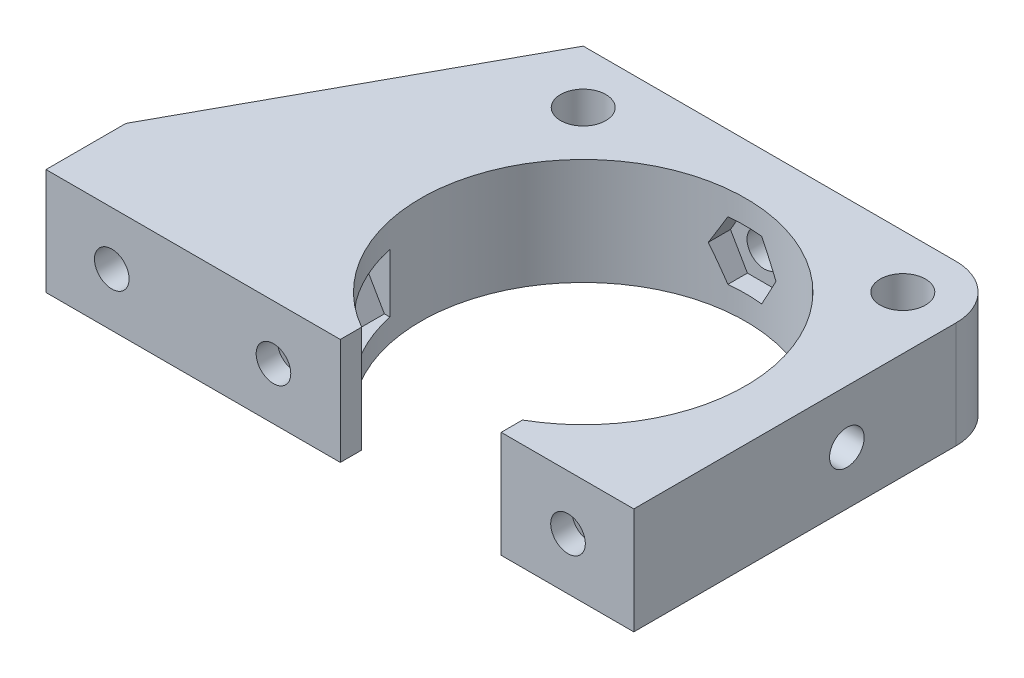
from build123d import *

# Parameters (mm, degrees)
CROQUIS1_R                              = 15.25
CROQUIS1_R_2                            = 2.125
SOPORTE_CAJA_REDUCTORA_DEPTH            = 20
CROQUIS3_R                              = 2.125
CORTAR_EXTRUIR1_DEPTH                   = 51.423828692
REDONDEO1_R                             = 5
BOSS_EXTRUDE1_DEPTH                     = 20
CUT_EXTRUDE1_REACH                      = 55.852
SKETCH2_R                               = 1.625
CUT_EXTRUDE2_DEPTH                      = 2
SKETCH4_R                               = 1.625
CUT_EXTRUDE3_DEPTH                      = 63.291652731
CUT_EXTRUDE4_START                      = -4.5
CUT_EXTRUDE4_DEPTH                      = 2
CROQUIS6_W                              = 4.75
CROQUIS6_H                              = 4.75
CORTAR_EXTRUIR17_DEPTH                  = 42.231056256
CROQUIS7_W                              = 60
CROQUIS7_H                              = 20
CORTAR_EXTRUIR18_DEPTH                  = 51.423828692
SALIENTE_EXTRUIR2_DEPTH                 = 49
SOPORTE_START                           = -15
SOPORTE_MOTOR_DEPTH                     = 15
CROQUIS12_R                             = 2.125
AGUJEROS_DE_SUJECION_A_BASE_DEPTH       = 84.087679592
TUERCA_START                            = -4
TUERCA_AGUJERO_DE_SUJECION_A_BASE_DEPTH = 10
SALIENTE_EXTRUIR4_DEPTH                 = 15
CORTAR_EXTRUIR19_DEPTH                  = 25
CROQUIS14_W                             = 50
CROQUIS14_H                             = 118
CORTAR_EXTRUIR22_DEPTH                  = 146.556045907
CROQUIS15_W                             = 10
CROQUIS15_H                             = 7
CORTAR_EXTRUIR23_DEPTH                  = 42.231056256
CORTAR_EXTRUIR24_DEPTH                  = 42.231056256
CROQUIS18_W                             = 40
CROQUIS18_H                             = 10
CORTAR_EXTRUIR25_DEPTH                  = 44.27311521
SALIENTE_EXTRUIR5_DEPTH                 = 10
CROQUIS20_R                             = 1
CORTAR_EXTRUIR26_DEPTH                  = 49.229270158
CORTAR_EXTRUIR27_REACH                  = 62.959
CORTAR_EXTRUIR27_END_RADIUS             = 15.25
CROQUIS21_R                             = 1.625
CROQUIS22_R                             = 2.125
CROQUIS22_R_2                           = 1
SALIENTE_EXTRUIR6_DEPTH                 = 10
CROQUIS23_R                             = 1.625
CORTAR_EXTRUIR28_DEPTH                  = 52.269508521
CORTAR_EXTRUIR29_START                  = -3
CORTAR_EXTRUIR29_DEPTH                  = 10
SALIENTE_EXTRUIR7_DEPTH                 = 10
CORTAR_EXTRUIR30_REACH                  = 72.235
CROQUIS27_R                             = 1.625
CORTAR_EXTRUIR31_REACH                  = 75.235
CORTAR_EXTRUIR31_START                  = -3
CORTAR_EXTRUIR32_REACH                  = 58.612
CROQUIS29_R                             = 1.625
CORTAR_EXTRUIR33_REACH                  = 61.112
CORTAR_EXTRUIR33_START                  = -2.5
CROQUIS35_W                             = 13.305418987
CROQUIS35_H                             = 6.826864192
CORTAR_EXTRUIR34_DEPTH                  = 63.931555098
CORTAR_EXTRUIR34_DEPTH_BACK             = 63.931555098
CORTAR_EXTRUIR35_START                  = -3
CORTAR_EXTRUIR35_DEPTH                  = 10
SALIENTE_EXTRUIR8_DEPTH                 = 10
SALIENTE_EXTRUIR9_DEPTH                 = 13
SALIENTE_EXTRUIR10_DEPTH                = 3
CROQUIS40_W                             = 106.583537839
CROQUIS40_H                             = 47.391515964
CORTAR_EXTRUIR36_DEPTH                  = 80.887064817
CORTAR_EXTRUIR36_DEPTH_BACK             = 80.887064817
CORTAR_EXTRUIR37_DEPTH                  = 67.2524009
CORTAR_EXTRUIR37_DEPTH_BACK             = 67.2524009
CORTAR_EXTRUIR38_DEPTH                  = 79.704784639
CORTAR_EXTRUIR38_DEPTH_BACK             = 79.704784639
SALIENTE_EXTRUIR11_DEPTH                = 10
CORTAR_EXTRUIR39_DEPTH                  = 63.9908649
CROQUIS45_W                             = 31.470301378
CROQUIS45_H                             = 10
CROQUIS45_R                             = 1.625
SALIENTE_EXTRUIR12_DEPTH                = 2.5
SALIENTE_EXTRUIR13_DEPTH                = 10
CORTAR_EXTRUIR40_START                  = -2
CROQUIS47_R                             = 1.625
CORTAR_EXTRUIR40_DEPTH                  = 10
CORTAR_EXTRUIR41_START                  = -12
CROQUIS48_R                             = 1.625
CORTAR_EXTRUIR41_DEPTH                  = 12
CORTAR_EXTRUIR42_DEPTH                  = 3
CROQUIS50_W                             = 80.415439526
CROQUIS50_H                             = 16.145703155
CORTAR_EXTRUIR43_DEPTH                  = 66.767385996
CORTAR_EXTRUIR43_DEPTH_BACK             = 66.767385996
CROQUIS51_R                             = 2.125
CORTAR_EXTRUIR44_DEPTH                  = 52.795622989
CORTAR_EXTRUIR44_DEPTH_BACK             = 52.795622989
CORTAR_EXTRUIR45_DEPTH                  = 52.795622989
CORTAR_EXTRUIR45_DEPTH_BACK             = 52.795622989
SALIENTE_EXTRUIR14_DEPTH                = 10
CORTAR_EXTRUIR46_START                  = -5.5
CORTAR_EXTRUIR46_DEPTH                  = 49.164449388


with BuildPart() as part:
    # Croquis1 → Soporte caja reductora (new body)
    with BuildSketch(Plane(origin=(0, 0, 0), x_dir=(1, 0, 0), z_dir=(0, 1, 0))):
        Polygon((-30, -15.25), (-20, -15.25), (-20, -20), (20, -20), (20, -15.25), (30, -15.25), (30, -7.25), (20, -4.25), (20, 20), (-20, 20), (-20, -4.25), (-30, -7.25), align=None)
        with Locations(Location((0, 0, 0), (0, 0, 270))):
            Circle(CROQUIS1_R, mode=Mode.SUBTRACT)
        with Locations(Location((-15, 15, 0), (0, 0, 270))):
            Circle(CROQUIS1_R_2, mode=Mode.SUBTRACT)
        with Locations(Location((15, 15, 0), (0, 0, 270))):
            Circle(CROQUIS1_R_2, mode=Mode.SUBTRACT)
    extrude(amount=-SOPORTE_CAJA_REDUCTORA_DEPTH)

    # Croquis3 → Cortar-Extruir1 (cut, through all)
    with BuildSketch(Plane.XY.offset(15.25)):
        with Locations((-23.5, -10)):
            Circle(CROQUIS3_R)
        with Locations((23.5, -10)):
            Circle(CROQUIS3_R)
    extrude(amount=-CORTAR_EXTRUIR1_DEPTH, mode=Mode.SUBTRACT)

    # Redondeo1
    redondeo1_edges = [part.edges().sort_by_distance(p)[0] for p in [
        (-20, -10, -20),
        (20, -10, -20),
    ]]
    fillet(redondeo1_edges, radius=REDONDEO1_R)

    # Sketch1 → Boss-Extrude1 (add)
    with BuildSketch(Plane(origin=(0, 0, 0), x_dir=(1, 0, 0), z_dir=(0, 1, 0))):
        with BuildLine():
            Line((25.5, 15), (20, 15))
            ThreePointArc((20, 15), (18.535533906, 18.535533906), (15, 20))
            Line((15, 20), (30, 20))
            Line((30, 20), (30, 8))
            Line((30, 8), (25.5, 8))
            Line((25.5, 8), (25.5, 15))
        make_face()
    extrude(amount=-BOSS_EXTRUDE1_DEPTH)

    # Sketch2 → Cut-Extrude1 (cut, up to next)
    with BuildSketch(Plane(origin=(0, 0, -20), x_dir=(-1, 0, 0), z_dir=(0, 0, -1)), mode=Mode.PRIVATE) as cut_extrude1_sk1:
        with Locations((-22.75, -10)):
            Circle(SKETCH2_R)
    cut_extrude1_tool1 = extrude(cut_extrude1_sk1.sketch, amount=-CUT_EXTRUDE1_REACH, mode=Mode.PRIVATE) & part.part
    add(cut_extrude1_tool1.solids().sort_by_distance((22.75, -10, -20))[0], mode=Mode.SUBTRACT)

    # Sketch3 → Cut-Extrude2 (cut)
    with BuildSketch(Plane.XY.offset(-15)):
        Polygon((20, -11.58771324), (22.75, -13.175426481), (25.5, -11.58771324), (25.5, -8.41228676), (22.75, -6.824573519), (20, -8.41228676), align=None)
    extrude(amount=-CUT_EXTRUDE2_DEPTH, mode=Mode.SUBTRACT)

    # Sketch4 → Cut-Extrude3 (cut, through all)
    with BuildSketch(Plane.ZY.offset(-25.5)):
        with Locations((-12.25, -10)):
            Circle(SKETCH4_R)
    extrude(amount=-CUT_EXTRUDE3_DEPTH, mode=Mode.SUBTRACT)

    # Sketch5 → Cut-Extrude4 (cut)
    with BuildSketch(Plane(origin=(30, 0, 0), x_dir=(0, 0, -1), z_dir=(1, 0, 0)).offset(CUT_EXTRUDE4_START)):
        Polygon((15, -11.58771324), (15, -8.41228676), (12.25, -6.824573519), (9.5, -8.41228676), (9.5, -11.58771324), (12.25, -13.175426481), align=None)
    extrude(amount=CUT_EXTRUDE4_DEPTH, mode=Mode.SUBTRACT)

    # Croquis6 → Cortar-Extruir17 (cut, through all)
    with BuildSketch(Plane(origin=(0, 0, 0), x_dir=(1, 0, 0), z_dir=(0, 1, 0))):
        Polygon((0, -15.25), (-15.25, -15.25), (-15.25, -20), (15.25, -20), (15.25, -15.25), align=None)
        with Locations((-17.625, -17.625)):
            Rectangle(CROQUIS6_W, CROQUIS6_H)
        with BuildLine():
            ThreePointArc((0, -15.25), (-10.783378413, -10.783378413), (-15.25, 0))
            Line((-15.25, 0), (-15.25, -15.25))
            Line((-15.25, -15.25), (0, -15.25))
        make_face()
        with BuildLine():
            Line((15.25, -15.25), (15.25, 0))
            ThreePointArc((15.25, 0), (10.783378413, -10.783378413), (0, -15.25))
            Line((0, -15.25), (15.25, -15.25))
        make_face()
        with Locations((17.625, -17.625)):
            Rectangle(CROQUIS6_W, CROQUIS6_H)
    extrude(amount=-CORTAR_EXTRUIR17_DEPTH, mode=Mode.SUBTRACT)


with BuildPart() as body_2:
    # Simetría1: mirrored copy
    add(part.part.mirror(Plane.ZX))

    # Croquis8 → Saliente-Extruir2 (add)
    with BuildSketch(Plane(origin=(0, 20, 0), x_dir=(1, 0, 0), z_dir=(0, 1, 0))):
        with BuildLine():
            Line((-12.664515522, 20), (-11.040489496, 13.939052358))
            Line((-11.040489496, 13.939052358), (-10.315162126, 11.232093763))
            ThreePointArc((-10.315162126, 11.232093763), (0, 15.25), (10.315162126, 11.232093763))
            Line((10.315162126, 11.232093763), (10.817418481, 13.87928066))
            Line((10.817418481, 13.87928066), (11.978715476, 20))
            Line((11.978715476, 20), (-12.664515522, 20))
        make_face()
    extrude(amount=SALIENTE_EXTRUIR2_DEPTH)

    # Croquis9 → Soporte motor (add)
    with BuildSketch(Plane(origin=(0, 69, 0), x_dir=(1, 0, 0), z_dir=(0, 1, 0)).offset(SOPORTE_START)):
        with BuildLine():
            Line((-20, 15), (-20, -4.25))
            Line((-20, -4.25), (-30, -7.25))
            Line((-30, -7.25), (-30, -15.25))
            Line((-30, -15.25), (0, -15.25))
            Line((0, -15.25), (0, -14.75))
            ThreePointArc((0, -14.75), (-10.429825023, 10.429825023), (14.75, 0))
            Line((14.75, 0), (20, 0))
            Line((20, 0), (20, 13.936837101))
            Line((20, 13.936837101), (12.664515522, 20))
            Line((12.664515522, 20), (-15, 20))
            ThreePointArc((-15, 20), (-18.535533906, 18.535533906), (-20, 15))
        make_face()
    extrude(amount=-SOPORTE_MOTOR_DEPTH)

    # Croquis12 → Agujeros de sujecion a base (cut, through all)
    with BuildSketch(Plane.XY.offset(15.25)):
        with Locations((-23.5, 46.5)):
            Circle(CROQUIS12_R)
    extrude(amount=-AGUJEROS_DE_SUJECION_A_BASE_DEPTH, mode=Mode.SUBTRACT)

    # Croquis13 → Tuerca Agujero de sujecion a base (cut)
    with BuildSketch(Plane.XY.offset(15.25).offset(TUERCA_START)):
        Polygon((-20, 44.479274058), (-20, 48.520725942), (-23.5, 50.541451884), (-27, 48.520725942), (-27, 44.479274058), (-23.5, 42.458548116), align=None)
    extrude(amount=-TUERCA_AGUJERO_DE_SUJECION_A_BASE_DEPTH, mode=Mode.SUBTRACT)

    # Croquis10 → Saliente-Extruir4 (add)
    with BuildSketch(Plane(origin=(0, 69, 0), x_dir=(1, 0, 0), z_dir=(0, 1, 0))):
        with BuildLine():
            ThreePointArc((10.315162126, 11.232093763), (0, 15.25), (-10.315162126, 11.232093763))
            Line((-10.315162126, 11.232093763), (-10.16850369, 10.684757026))
            ThreePointArc((-10.16850369, 10.684757026), (0, 14.75), (10.16850369, 10.684757026))
            Line((10.16850369, 10.684757026), (10.315162126, 11.232093763))
        make_face()
    extrude(amount=-SALIENTE_EXTRUIR4_DEPTH)

    # Croquis11 → Cortar-Extruir19 (cut)
    with BuildSketch(Plane.XZ):
        with BuildLine():
            Line((15.25, 4.25), (20, 4.25))
            Line((20, 4.25), (21.972856468, 4.84185694))
            ThreePointArc((21.972856468, 4.84185694), (19.948931102, 10.40625523), (16.543503257, 15.25))
            Line((16.543503257, 15.25), (15.25, 15.25))
            Line((15.25, 15.25), (15.25, 4.25))
        make_face()
        with BuildLine():
            Line((21.972856468, 4.84185694), (30, 7.25))
            Line((30, 7.25), (30, 15.25))
            Line((30, 15.25), (16.543503257, 15.25))
            ThreePointArc((16.543503257, 15.25), (19.948931102, 10.40625523), (21.972856468, 4.84185694))
        make_face()
        with BuildLine():
            ThreePointArc((20, -15), (18.535533906, -18.535533906), (15, -20))
            Line((15, -20), (30, -20))
            Line((30, -20), (30, -8))
            Line((30, -8), (25.5, -8))
            Line((25.5, -8), (25.5, -15))
            Line((25.5, -15), (20, -15))
        make_face()
    extrude(amount=-CORTAR_EXTRUIR19_DEPTH, mode=Mode.SUBTRACT)

    # Simetría2: body 2 across face


with BuildPart() as part_1:
    add(part.part)

    # Croquis7 → Cortar-Extruir18 (cut, through all)
    with BuildSketch(Plane(origin=(0, 0, -20), x_dir=(-1, 0, 0), z_dir=(0, 0, -1))):
        with Locations((0, -10)):
            Rectangle(CROQUIS7_W, CROQUIS7_H)
    extrude(amount=-CORTAR_EXTRUIR18_DEPTH, mode=Mode.SUBTRACT)


with BuildPart() as body_2_1:
    add(body_2.part)
    add(body_2.part.mirror(Plane(origin=(-0.229209569, 69, -16.663998028), x_dir=(0, 0, 1), z_dir=(0, 1, 0))))

    # Croquis14 → Cortar-Extruir22 (cut, through all)
    with BuildSketch(Plane.XY.offset(15.25)):
        with Locations((-5, 79)):
            Rectangle(CROQUIS14_W, CROQUIS14_H)
    extrude(amount=-CORTAR_EXTRUIR22_DEPTH, mode=Mode.SUBTRACT)

    # Croquis15 → Cortar-Extruir23 (cut, through all)
    with BuildSketch(Plane.XZ):
        with Locations((-25, 7.75)):
            Rectangle(CROQUIS15_W, CROQUIS15_H)
    extrude(amount=-CORTAR_EXTRUIR23_DEPTH, mode=Mode.SUBTRACT)

    # Croquis16 → Cortar-Extruir24 (cut, through all)
    with BuildSketch(Plane.XZ):
        Polygon((-30, 15.25), (-15.25, 15.25), (-15.25, 12.75), (-20, 12.75), (-20, 11.25), (-30, 11.25), (-30, 12.75), align=None)
    extrude(amount=-CORTAR_EXTRUIR24_DEPTH, mode=Mode.SUBTRACT)

    # Croquis18 → Cortar-Extruir25 (cut, through all)
    with BuildSketch(Plane(origin=(0, 0, -20), x_dir=(-1, 0, 0), z_dir=(0, 0, -1))):
        with Locations((0, 5)):
            Rectangle(CROQUIS18_W, CROQUIS18_H)
    extrude(amount=-CORTAR_EXTRUIR25_DEPTH, mode=Mode.SUBTRACT)

    # Croquis19 → Saliente-Extruir5 (add)
    with BuildSketch(Plane(origin=(0, 20, 0), x_dir=(1, 0, 0), z_dir=(0, 1, 0))):
        Polygon((-20, -12.75), (-34, -12.75), (-34, -7.75), (-24, -7.75), (-20, -3.75), align=None)
    extrude(amount=-SALIENTE_EXTRUIR5_DEPTH)

    # Croquis20 → Cortar-Extruir26 (cut, through all)
    with BuildSketch(Plane(origin=(0, 0, 7.75), x_dir=(-1, 0, 0), z_dir=(0, 0, -1))):
        with Locations((29, 15)):
            Circle(CROQUIS20_R)
    extrude(amount=-CORTAR_EXTRUIR26_DEPTH, mode=Mode.SUBTRACT)

    # Cortar-Extruir27: up to this cylinder (the profile starts outside it)
    cortar_extruir27_end = Plane(origin=(0, 15, 0), z_dir=(0, -1, 0)) * Cylinder(CORTAR_EXTRUIR27_END_RADIUS, 157.418, mode=Mode.PRIVATE)
    # Croquis21 → Cortar-Extruir27 (cut, up to the surface)
    with BuildSketch(Plane(origin=(20, 0, 0), x_dir=(0, 0, -1), z_dir=(1, 0, 0)), mode=Mode.PRIVATE) as cortar_extruir27_sk1:
        with Locations((4.75, 15)):
            Circle(CROQUIS21_R)
    cortar_extruir27_tool1 = extrude(cortar_extruir27_sk1.sketch, amount=-CORTAR_EXTRUIR27_REACH, mode=Mode.PRIVATE) - cortar_extruir27_end
    add(cortar_extruir27_tool1.solids().sort_by_distance((20, 15, -4.75))[0], mode=Mode.SUBTRACT)

    # Croquis22 → Saliente-Extruir6 (add)
    with BuildSketch(Plane.XZ.offset(-10)):
        with Locations((-15, -15)):
            Circle(CROQUIS22_R)
        with Locations(Location((-15, -15, 0), (0, 0, 270))):
            Circle(CROQUIS22_R_2, mode=Mode.SUBTRACT)
        with Locations((15, -15)):
            Circle(CROQUIS22_R)
        with Locations(Location((15, -15, 0), (0, 0, 270))):
            Circle(CROQUIS22_R_2, mode=Mode.SUBTRACT)
    extrude(amount=-SALIENTE_EXTRUIR6_DEPTH)

    # Croquis23 → Cortar-Extruir28 (cut, through all)
    with BuildSketch(Plane(origin=(0, 0, -20), x_dir=(-1, 0, 0), z_dir=(0, 0, -1))):
        with Locations((0, 15)):
            Circle(CROQUIS23_R)
    extrude(amount=-CORTAR_EXTRUIR28_DEPTH, mode=Mode.SUBTRACT)

    # Croquis24 → Cortar-Extruir29 (cut)
    with BuildSketch(Plane(origin=(0, 0, -20), x_dir=(-1, 0, 0), z_dir=(0, 0, -1)).offset(CORTAR_EXTRUIR29_START)):
        Polygon((1.58771324, 12.25), (3.175426481, 15), (1.58771324, 17.75), (-1.58771324, 17.75), (-3.175426481, 15), (-1.58771324, 12.25), align=None)
    extrude(amount=-CORTAR_EXTRUIR29_DEPTH, mode=Mode.SUBTRACT)

    # Croquis26 → Saliente-Extruir7 (add)
    with BuildSketch(Plane.XZ.offset(-10)):
        Polygon((-34, 7.75), (-34, 12.75), (-58.825, 12.75), (-39.160527763, -4.104491148), (-20, -4.104491148), (-20, -0.104491148), (-35.732113118, -0.104491148), (-29, 7.75), align=None)
        Polygon((-34.268209086, 7.75), (-39.594516123, 1.535690951), (-46.844874897, 7.75), align=None, mode=Mode.SUBTRACT)
    extrude(amount=-SALIENTE_EXTRUIR7_DEPTH)

    # Croquis27 → Cortar-Extruir30 (cut, up to next)
    with BuildSketch(Plane.XY.offset(12.75), mode=Mode.PRIVATE) as cortar_extruir30_sk1:
        with Locations((-40.544874897, 15)):
            Circle(CROQUIS27_R)
    cortar_extruir30_tool1 = extrude(cortar_extruir30_sk1.sketch, amount=-CORTAR_EXTRUIR30_REACH, mode=Mode.PRIVATE) & body_2_1.part
    # Croquis27 → Cortar-Extruir30 (cut, up to next)
    with BuildSketch(Plane.XY.offset(12.75), mode=Mode.PRIVATE) as cortar_extruir30_sk2:
        with Locations((-29, 15)):
            Circle(CROQUIS27_R)
    cortar_extruir30_tool2 = extrude(cortar_extruir30_sk2.sketch, amount=-CORTAR_EXTRUIR30_REACH, mode=Mode.PRIVATE) & body_2_1.part
    add(cortar_extruir30_tool1.solids().sort_by_distance((-40.544875, 15, 12.75))[0], mode=Mode.SUBTRACT)
    add(cortar_extruir30_tool2.solids().sort_by_distance((-29, 15, 12.75))[0], mode=Mode.SUBTRACT)

    # Croquis28 → Cortar-Extruir31 (cut, up to next)
    with BuildSketch(Plane.XY.offset(12.75).offset(CORTAR_EXTRUIR31_START), mode=Mode.PRIVATE) as cortar_extruir31_sk1:
        Polygon((-38.957161657, 12.25), (-37.369448416, 15), (-38.957161657, 17.75), (-42.132588137, 17.75), (-43.720301378, 15), (-42.132588137, 12.25), align=None)
    cortar_extruir31_tool1 = extrude(cortar_extruir31_sk1.sketch, amount=-CORTAR_EXTRUIR31_REACH, mode=Mode.PRIVATE) & body_2_1.part
    # Croquis28 → Cortar-Extruir31 (cut, up to next)
    with BuildSketch(Plane.XY.offset(12.75).offset(CORTAR_EXTRUIR31_START), mode=Mode.PRIVATE) as cortar_extruir31_sk2:
        Polygon((-27.41228676, 12.25), (-25.824573519, 15), (-27.41228676, 17.75), (-30.58771324, 17.75), (-32.175426481, 15), (-30.58771324, 12.25), align=None)
    cortar_extruir31_tool2 = extrude(cortar_extruir31_sk2.sketch, amount=-CORTAR_EXTRUIR31_REACH, mode=Mode.PRIVATE) & body_2_1.part
    add(cortar_extruir31_tool1.solids().sort_by_distance((-40.544875, 15, 9.75))[0], mode=Mode.SUBTRACT)
    add(cortar_extruir31_tool2.solids().sort_by_distance((-29, 15, 9.75))[0], mode=Mode.SUBTRACT)

    # Croquis29 → Cortar-Extruir32 (cut, up to next)
    with BuildSketch(Plane(origin=(-18.612848159, 0, -21.715982563), x_dir=(-0.7592713073348843, 0, 0.6507742172658468), z_dir=(-0.6507742172658468, 0, -0.7592713073348843)), mode=Mode.PRIVATE) as cortar_extruir32_sk1:
        with Locations((33.812368097, 15)):
            Circle(CROQUIS29_R)
    cortar_extruir32_tool1 = extrude(cortar_extruir32_sk1.sketch, amount=-CORTAR_EXTRUIR32_REACH, mode=Mode.PRIVATE) & body_2_1.part
    add(cortar_extruir32_tool1.solids().sort_by_distance((-44.285609, 15, 0.288235))[0], mode=Mode.SUBTRACT)

    # Croquis31 → Cortar-Extruir33 (cut, up to next)
    with BuildSketch(Plane(origin=(-18.612848159, 0, -21.715982563), x_dir=(-0.7592713073348843, 0, 0.6507742172658468), z_dir=(-0.6507742172658468, 0, -0.7592713073348843)).offset(CORTAR_EXTRUIR33_START), mode=Mode.PRIVATE) as cortar_extruir33_sk1:
        Polygon((36.562368097, 16.58771324), (33.812368097, 18.175426481), (31.062368097, 16.58771324), (31.062368097, 13.41228676), (33.812368097, 11.824573519), (36.562368097, 13.41228676), align=None)
    cortar_extruir33_tool1 = extrude(cortar_extruir33_sk1.sketch, amount=-CORTAR_EXTRUIR33_REACH, mode=Mode.PRIVATE) & body_2_1.part
    add(cortar_extruir33_tool1.solids().sort_by_distance((-42.658674, 15, 2.186413))[0], mode=Mode.SUBTRACT)

    # Croquis35 → Cortar-Extruir34 (cut, two sides)
    with BuildSketch(Plane(origin=(0, 20, 0), x_dir=(1, 0, 0), z_dir=(0, 1, 0))) as cortar_extruir34_sk:
        with Locations((17.04227466, -3.413432096)):
            Rectangle(CROQUIS35_W, CROQUIS35_H)
    extrude(amount=CORTAR_EXTRUIR34_DEPTH, mode=Mode.SUBTRACT)
    extrude(cortar_extruir34_sk.sketch, amount=-CORTAR_EXTRUIR34_DEPTH_BACK, mode=Mode.SUBTRACT)

    # Croquis36 → Cortar-Extruir35 (cut)
    with BuildSketch(Plane(origin=(20, 0, 0), x_dir=(0, 0, -1), z_dir=(1, 0, 0)).offset(CORTAR_EXTRUIR35_START)):
        Polygon((7.5, 16.58771324), (4.75, 18.175426481), (2, 16.58771324), (2, 13.41228676), (4.75, 11.824573519), (7.5, 13.41228676), align=None)
    extrude(amount=-CORTAR_EXTRUIR35_DEPTH, mode=Mode.SUBTRACT)

    # Croquis37 → Saliente-Extruir8 (add)
    with BuildSketch(Plane.XZ.offset(-10)):
        Polygon((-39.160527763, -4.104491148), (-20.614919368, -20), (-15, -20), (-19.558128305, -15.637570403), (-33.014002756, -4.104491148), align=None)
    extrude(amount=-SALIENTE_EXTRUIR8_DEPTH)

    # Croquis38 → Saliente-Extruir9 (add)
    with BuildSketch(Plane.XZ.offset(-10)):
        Polygon((-58.825, 12.75), (-38.825, 12.75), (-38.825, 9.75), (-55.324839942, 9.75), align=None)
    extrude(amount=SALIENTE_EXTRUIR9_DEPTH)

    # Croquis39 → Saliente-Extruir10 (add)
    with BuildSketch(Plane.XZ.offset(-10)):
        Polygon((-38.825, 9.75), (-38.825, 7.75), (-38.825, 5.75), (-50.657959865, 5.75), (-52.991399903, 7.75), (-55.324839942, 9.75), align=None)
    extrude(amount=SALIENTE_EXTRUIR10_DEPTH)

    # Simetría3: body 2 across face


with BuildPart() as body_2_2:
    add(body_2_1.part)
    add(body_2_1.part.mirror(Plane(origin=(-18.003999227, 20, -4.220503046), x_dir=(0, 0, 1), z_dir=(0, 1, 0))))

    # Croquis40 → Cortar-Extruir36 (cut, two sides)
    with BuildSketch(Plane(origin=(0, 0, -20), x_dir=(-1, 0, 0), z_dir=(0, 0, -1))) as cortar_extruir36_sk:
        with Locations((22.395502026, -3.695757982)):
            Rectangle(CROQUIS40_W, CROQUIS40_H)
    extrude(amount=CORTAR_EXTRUIR36_DEPTH, mode=Mode.SUBTRACT)
    extrude(cortar_extruir36_sk.sketch, amount=-CORTAR_EXTRUIR36_DEPTH_BACK, mode=Mode.SUBTRACT)

    # Croquis41 → Cortar-Extruir37 (cut, two sides)
    with BuildSketch(Plane.XZ.offset(-20)) as cortar_extruir37_sk:
        Polygon((-19.992980133, -22.302484261), (-20, 3.75), (-24, 7.75), (-56.035110209, 7.75), align=None)
    extrude(amount=CORTAR_EXTRUIR37_DEPTH, mode=Mode.SUBTRACT)
    extrude(cortar_extruir37_sk.sketch, amount=-CORTAR_EXTRUIR37_DEPTH_BACK, mode=Mode.SUBTRACT)

    # Croquis42 → Cortar-Extruir38 (cut, two sides)
    with BuildSketch(Plane(origin=(0, 0, 9.75), x_dir=(-1, 0, 0), z_dir=(0, 0, -1))) as cortar_extruir38_sk:
        Polygon((46.720301378, 20), (46.720301378, 30), (38.825, 30), (33.492952769, 43.760628779), (49.525340398, 48.951442806), (67.200390695, 42.512205152), (65.906601328, 20), (51.713995885, 13.864168239), align=None)
    extrude(amount=CORTAR_EXTRUIR38_DEPTH, mode=Mode.SUBTRACT)
    extrude(cortar_extruir38_sk.sketch, amount=-CORTAR_EXTRUIR38_DEPTH_BACK, mode=Mode.SUBTRACT)

    # Croquis43 → Saliente-Extruir11 (add)
    with BuildSketch(Plane.XZ.offset(-20)):
        Polygon((-19.993600539, -20), (-46.720301378, 7.75), (-43.839252857, 10.524807997), (-17.112552018, -17.225192003), align=None)
    extrude(amount=-SALIENTE_EXTRUIR11_DEPTH)

    # Croquis44 → Cortar-Extruir39 (cut, through all)
    with BuildSketch(Plane(origin=(0, 0, 9.75), x_dir=(-1, 0, 0), z_dir=(0, 0, -1))):
        Polygon((38.957161657, 27.75), (37.369448416, 25), (38.957161657, 22.25), (42.132588137, 22.25), (43.720301378, 25), (42.132588137, 27.75), align=None)
    extrude(amount=CORTAR_EXTRUIR39_DEPTH, mode=Mode.SUBTRACT)

    # Croquis45 → Saliente-Extruir12 (add)
    with BuildSketch(Plane.XY.offset(12.75)):
        with Locations((-30.985150689, 25)):
            Rectangle(CROQUIS45_W, CROQUIS45_H)
        with Locations((-40.544874897, 25)):
            Circle(CROQUIS45_R, mode=Mode.SUBTRACT)
        with Locations((-29, 25)):
            Circle(CROQUIS45_R, mode=Mode.SUBTRACT)
    extrude(amount=SALIENTE_EXTRUIR12_DEPTH)

    # Croquis46 → Saliente-Extruir13 (add)
    with BuildSketch(Plane.XZ.offset(-20)):
        with BuildLine():
            Line((15.25, 0), (20, 0))
            Line((20, 0), (20, 15.25))
            Line((20, 15.25), (7.549834435, 15.25))
            Line((7.549834435, 15.25), (7.549834435, 13.25))
            ThreePointArc((7.549834435, 13.25), (13.185171124, 7.662490615), (15.25, 0))
        make_face()
        with BuildLine():
            Line((-15.25, 0), (-15.25, 15.25))
            Line((-15.25, 15.25), (-7.549834435, 15.25))
            Line((-7.549834435, 15.25), (-7.549834435, 13.25))
            ThreePointArc((-7.549834435, 13.25), (-13.185171124, 7.662490615), (-15.25, 0))
        make_face()
    extrude(amount=-SALIENTE_EXTRUIR13_DEPTH)

    # Croquis47 → Cortar-Extruir40 (cut)
    with BuildSketch(Plane.XY.offset(15.25).offset(CORTAR_EXTRUIR40_START)):
        Polygon((15.41228676, 22.352505966), (17, 25.102505966), (15.41228676, 27.852505966), (12.236860279, 27.852505966), (10.649147039, 25.102505966), (12.236860279, 22.352505966), align=None)
        with Locations((13.824573519, 25.102505966)):
            Circle(CROQUIS47_R, mode=Mode.SUBTRACT)
        Polygon((-12.236860279, 22.352505966), (-15.41228676, 22.352505966), (-17, 25.102505966), (-15.41228676, 27.852505966), (-12.236860279, 27.852505966), (-10.649147039, 25.102505966), align=None)
        with Locations(Location((-13.824573519, 25.102505966, 0), (0, 0, 131.421584744))):
            Circle(CROQUIS47_R, mode=Mode.SUBTRACT)
    extrude(amount=-CORTAR_EXTRUIR40_DEPTH, mode=Mode.SUBTRACT)

    # Croquis48 → Cortar-Extruir41 (cut)
    with BuildSketch(Plane.XY.offset(15.25).offset(CORTAR_EXTRUIR41_START)):
        with Locations((13.824573519, 25.102505966)):
            Circle(CROQUIS48_R)
        with Locations((-13.824573519, 25.102505966)):
            Circle(CROQUIS48_R)
    extrude(amount=CORTAR_EXTRUIR41_DEPTH, mode=Mode.SUBTRACT)

    # Croquis49 → Cortar-Extruir42 (cut)
    with BuildSketch(Plane(origin=(0, 30, 0), x_dir=(1, 0, 0), z_dir=(0, 1, 0))):
        Polygon((-12.979274058, 11.5), (-10.958548116, 15), (-12.979274058, 18.5), (-17.020725942, 18.5), (-19.041451884, 15), (-17.020725942, 11.5), align=None)
        Polygon((17.020725942, 11.5), (19.041451884, 15), (17.020725942, 18.5), (12.979274058, 18.5), (10.958548116, 15), (12.979274058, 11.5), align=None)
    extrude(amount=-CORTAR_EXTRUIR42_DEPTH, mode=Mode.SUBTRACT)

    # Simetría4: body 2 across plane


with BuildPart() as body_2_3:
    add(body_2_2.part)
    add(body_2_2.part.mirror(Plane(origin=(30.896266894, 20, 12.75), x_dir=(0, 0, 1), z_dir=(0, 1, 0))))

    # Croquis50 → Cortar-Extruir43 (cut, two sides)
    with BuildSketch(Plane(origin=(0, 0, -20), x_dir=(-1, 0, 0), z_dir=(0, 0, -1))) as cortar_extruir43_sk:
        with Locations((12.268612219, 28.072851577)):
            Rectangle(CROQUIS50_W, CROQUIS50_H)
    extrude(amount=CORTAR_EXTRUIR43_DEPTH, mode=Mode.SUBTRACT)
    extrude(cortar_extruir43_sk.sketch, amount=-CORTAR_EXTRUIR43_DEPTH_BACK, mode=Mode.SUBTRACT)

    # Croquis51 → Cortar-Extruir44 (cut, two sides)
    with BuildSketch(Plane.XZ.offset(-10)) as cortar_extruir44_sk:
        with Locations(Location((-15, -15, 0), (0, 0, 270))):
            Circle(CROQUIS51_R)
        with Locations(Location((15, -15, 0), (0, 0, 270))):
            Circle(CROQUIS51_R)
    extrude(amount=CORTAR_EXTRUIR44_DEPTH, mode=Mode.SUBTRACT)
    extrude(cortar_extruir44_sk.sketch, amount=-CORTAR_EXTRUIR44_DEPTH_BACK, mode=Mode.SUBTRACT)

    # Croquis52 → Cortar-Extruir45 (cut, two sides)
    with BuildSketch(Plane.XZ.offset(-10)) as cortar_extruir45_sk:
        Polygon((-35.175426481, 15.25), (-35.175426481, 7.75), (-19.995154673, -14.232221634), (-19.993600539, -20), (-54.542897094, 5.516026969), (-50.455586096, 20.949060485), align=None)
    extrude(amount=CORTAR_EXTRUIR45_DEPTH, mode=Mode.SUBTRACT)
    extrude(cortar_extruir45_sk.sketch, amount=-CORTAR_EXTRUIR45_DEPTH_BACK, mode=Mode.SUBTRACT)

    # Croquis53 → Saliente-Extruir14 (add)
    with BuildSketch(Plane.XZ.offset(-10)):
        Polygon((-35.175426481, 7.75), (-19.993600539, -20), (-20, 3.75), (-24, 7.75), align=None)
    extrude(amount=-SALIENTE_EXTRUIR14_DEPTH)

    # Croquis54 → Cortar-Extruir46 (cut, through all)
    with BuildSketch(Plane.XY.offset(15.25).offset(CORTAR_EXTRUIR46_START)):
        Polygon((-27.41228676, 17.75), (-30.58771324, 17.75), (-32.175426481, 15), (-30.58771324, 12.25), (-27.41228676, 12.25), (-25.824573519, 15), align=None)
    extrude(amount=-CORTAR_EXTRUIR46_DEPTH, mode=Mode.SUBTRACT)


solid = body_2_3.part
